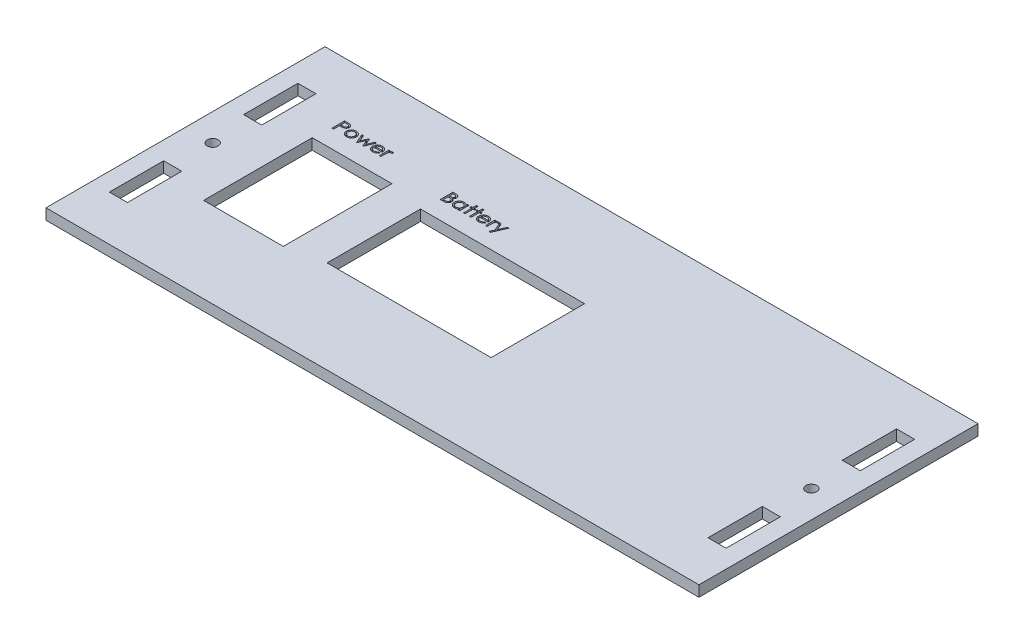
from build123d import *

# Parameters (mm, degrees)
SCHIZZO1_W                   = 180.34
SCHIZZO1_H                   = 77.07
ESTRUSIONE_ESTRUSIONE1_DEPTH = 3
SCHIZZO2_R                   = 1.5
SCHIZZO2_W                   = 5
SCHIZZO2_H                   = 15
TAGLIO_ESTRUSIONE1_DEPTH     = 4
SCHIZZO3_W                   = 45.3
SCHIZZO3_H                   = 25.8
SCHIZZO3_W_2                 = 22
SCHIZZO3_H_2                 = 30
TAGLIO_ESTRUSIONE2_DEPTH     = 4
TAGLIO_ESTRUSIONE3_DEPTH     = 1
TAGLIO_ESTRUSIONE4_DEPTH     = 1


with BuildPart() as part:
    # Schizzo1 → Estrusione-Estrusione1 (new body)
    with BuildSketch(Plane(origin=(0, 0, 0), x_dir=(1, 0, 0), z_dir=(0, 1, 0))):
        Rectangle(SCHIZZO1_W, SCHIZZO1_H)
    extrude(amount=ESTRUSIONE_ESTRUSIONE1_DEPTH)

    # Schizzo2 → Taglio-Estrusione1 (cut, through all)
    with BuildSketch(Plane(origin=(0, 0, 0), x_dir=(1, 0, 0), z_dir=(0, 1, 0))):
        with Locations((-82.67, 0)):
            Circle(SCHIZZO2_R)
        with Locations((82.67, 0)):
            Circle(SCHIZZO2_R)
        with Locations((-82.67, 18.535)):
            Rectangle(SCHIZZO2_W, SCHIZZO2_H)
        with Locations((-82.67, -18.535)):
            Rectangle(SCHIZZO2_W, SCHIZZO2_H)
        with Locations((82.67, -18.535)):
            Rectangle(SCHIZZO2_W, SCHIZZO2_H)
        with Locations((82.67, 18.535)):
            Rectangle(SCHIZZO2_W, SCHIZZO2_H)
    extrude(amount=TAGLIO_ESTRUSIONE1_DEPTH, mode=Mode.SUBTRACT)

    # Schizzo3 → Taglio-Estrusione2 (cut, through all)
    with BuildSketch(Plane(origin=(0, 0, 0), x_dir=(1, 0, 0), z_dir=(0, 1, 0))):
        with Locations((-15.52, 0)):
            Rectangle(SCHIZZO3_W, SCHIZZO3_H)
        with Locations((-59.17, 0)):
            Rectangle(SCHIZZO3_W_2, SCHIZZO3_H_2)
    extrude(amount=TAGLIO_ESTRUSIONE2_DEPTH, mode=Mode.SUBTRACT)

    # Schizzo4 → Taglio-Estrusione3 (cut)
    with BuildSketch(Plane(origin=(0, 3, 0), x_dir=(1, 0, 0), z_dir=(0, 1, 0))):
        with BuildLine():
            Line((-37.721282051, 21.4), (-37.010344551, 21.4))
            add(Edge.make_bspline(
                [(-37.010344551, 21.4), (-36.975512489, 21.399880445), (-36.907901877, 21.399648383), (-36.809468419, 21.393576376), (-36.716881837, 21.385217637), (-36.629900509, 21.374684472), (-36.549090313, 21.358760238), (-36.474003053, 21.341039616), (-36.404852856, 21.319273206), (-36.32181816, 21.285928555), (-36.22684833, 21.236763452), (-36.12618551, 21.162915024), (-36.038636629, 21.07645617), (-35.966219425, 20.977667295), (-35.908930469, 20.870498168), (-35.866837195, 20.757921064), (-35.841651906, 20.640627626), (-35.838334155, 20.560876083), (-35.836666667, 20.520793269)],
                knots=[0, 0, 0, 0, 0.000104477, 0.000202794, 0.000295723, 0.000383383, 0.000465474, 0.000542677, 0.000614743, 0.000682705, 0.000810972, 0.000934377, 0.001055841, 0.001178682, 0.001300389, 0.001419294, 0.00153824, 0.001658426, 0.001658426, 0.001658426, 0.001658426], degree=3))
            add(Edge.make_bspline(
                [(-35.836666667, 20.520793269), (-35.838097439, 20.483316811), (-35.840925182, 20.409249289), (-35.861017361, 20.300045305), (-35.894740632, 20.195158689), (-35.941805515, 20.096228704), (-35.998673946, 20.004881066), (-36.068761704, 19.927059819), (-36.147555195, 19.860768065), (-36.207610576, 19.828721119), (-36.237708333, 19.812660256)],
                knots=[0, 0, 0, 0, 0.000112398, 0.000222141, 0.000331895, 0.00044198, 0.000550119, 0.00065341, 0.000755032, 0.000857129, 0.000857129, 0.000857129, 0.000857129], degree=3))
            add(Edge.make_bspline(
                [(-36.237708333, 19.812660256), (-36.201903156, 19.800772337), (-36.132238439, 19.777642484), (-36.034681131, 19.731486439), (-35.946353959, 19.677660249), (-35.868124222, 19.614722255), (-35.799552695, 19.544896005), (-35.738426844, 19.47013794), (-35.686314196, 19.389282289), (-35.643948432, 19.302651098), (-35.60900148, 19.212570596), (-35.585697898, 19.11852298), (-35.570121078, 19.022079984), (-35.56833643, 18.956652487), (-35.567435897, 18.923637821)],
                knots=[0, 0, 0, 0, 0.000113096, 0.000220046, 0.00032298, 0.000422732, 0.000520399, 0.000616102, 0.000711981, 0.000808242, 0.000904992, 0.00100124, 0.001098415, 0.001197395, 0.001197395, 0.001197395, 0.001197395], degree=3))
            add(Edge.make_bspline(
                [(-35.567435897, 18.923637821), (-35.568373631, 18.88946805), (-35.570225923, 18.821972997), (-35.585135888, 18.722434596), (-35.610833484, 18.626804781), (-35.644974124, 18.534107631), (-35.690420006, 18.445507835), (-35.745386093, 18.360259095), (-35.810399726, 18.278738965), (-35.884095559, 18.201278669), (-35.966688213, 18.130332131), (-36.057305054, 18.068652309), (-36.155095664, 18.016330709), (-36.260040649, 17.973323162), (-36.372738829, 17.940781259), (-36.492313636, 17.916867379), (-36.619018961, 17.902850181), (-36.705789048, 17.900965328), (-36.750228365, 17.9)],
                knots=[0, 0, 0, 0, 0.000102481, 0.00020243, 0.000301067, 0.000399128, 0.000498213, 0.000599147, 0.000702951, 0.000810562, 0.000919461, 0.001028946, 0.001138734, 0.001251617, 0.001368536, 0.001490087, 0.001617066, 0.001750369, 0.001750369, 0.001750369, 0.001750369], degree=3))
            Line((-36.750228365, 17.9), (-37.721282051, 17.9))
            Line((-37.721282051, 17.9), (-37.721282051, 21.4))
        make_face()
        with BuildLine():
            Line((-37.272564103, 20.996153846), (-37.272564103, 19.964102564))
            Line((-37.272564103, 19.964102564), (-37.159683494, 19.964102564))
            add(Edge.make_bspline(
                [(-37.159683494, 19.964102564), (-37.130464212, 19.96408051), (-37.074338657, 19.964038149), (-36.993242775, 19.968072108), (-36.918393486, 19.972582628), (-36.84959971, 19.979447893), (-36.78722123, 19.988761286), (-36.730607698, 19.998736631), (-36.680586197, 20.012102039), (-36.622537206, 20.031433106), (-36.558319564, 20.062133955), (-36.489104124, 20.107314707), (-36.428771312, 20.161983159), (-36.377929364, 20.225144014), (-36.336204248, 20.294303656), (-36.306819661, 20.368471797), (-36.288265652, 20.446265232), (-36.286354631, 20.499420924), (-36.285384615, 20.526402244)],
                knots=[0, 0, 0, 0, 8.7643e-05, 0.000168348, 0.000243529, 0.000312595, 0.000375657, 0.000432725, 0.000484933, 0.000530829, 0.000616135, 0.000697613, 0.000778026, 0.000859274, 0.000940077, 0.001019366, 0.001097772, 0.001178596, 0.001178596, 0.001178596, 0.001178596], degree=3))
            add(Edge.make_bspline(
                [(-36.285384615, 20.526402244), (-36.285634902, 20.544200578), (-36.286124866, 20.579042867), (-36.294431679, 20.62944457), (-36.305994173, 20.677388781), (-36.323720561, 20.721922497), (-36.345587657, 20.763896296), (-36.372412414, 20.802990571), (-36.40502718, 20.838425413), (-36.441607342, 20.871956681), (-36.484090624, 20.901734181), (-36.532961437, 20.926550351), (-36.587438684, 20.948789004), (-36.6485148, 20.96558324), (-36.715635846, 20.979951636), (-36.78903247, 20.989351791), (-36.868631587, 20.994882044), (-36.923629504, 20.995719527), (-36.952151442, 20.996153846)],
                knots=[0, 0, 0, 0, 5.3327e-05, 0.000104393, 0.000152857, 0.000201031, 0.000247759, 0.00029463, 0.000342783, 0.000391927, 0.000443276, 0.000497842, 0.00055604, 0.000619506, 0.000687572, 0.000761842, 0.000841267, 0.000926829, 0.000926829, 0.000926829, 0.000926829], degree=3))
            Line((-36.952151442, 20.996153846), (-37.272564103, 20.996153846))
        make_face(mode=Mode.SUBTRACT)
        with BuildLine():
            Line((-37.272564103, 19.56025641), (-37.272564103, 18.303846154))
            Line((-37.272564103, 18.303846154), (-36.929014423, 18.303846154))
            add(Edge.make_bspline(
                [(-36.929014423, 18.303846154), (-36.898865922, 18.304238817), (-36.8406601, 18.304996906), (-36.756685706, 18.307296665), (-36.67906548, 18.313117782), (-36.607961618, 18.320659123), (-36.543018276, 18.330079436), (-36.485122777, 18.342963233), (-36.433096486, 18.356573094), (-36.373216733, 18.378807692), (-36.306200799, 18.413291383), (-36.233333251, 18.463240598), (-36.170069139, 18.524355432), (-36.115612678, 18.593476378), (-36.07127903, 18.668850002), (-36.039718232, 18.748563163), (-36.019692229, 18.831043445), (-36.01733736, 18.887067636), (-36.016153846, 18.915224359)],
                knots=[0, 0, 0, 0, 9.0456e-05, 0.000174637, 0.000251964, 0.000323893, 0.000389139, 0.000448685, 0.000501753, 0.000550333, 0.000640011, 0.000727145, 0.000814422, 0.000902789, 0.000990451, 0.001075729, 0.001159233, 0.001243604, 0.001243604, 0.001243604, 0.001243604], degree=3))
            add(Edge.make_bspline(
                [(-36.016153846, 18.915224359), (-36.017560683, 18.950470246), (-36.020323742, 19.019693993), (-36.048489164, 19.119385816), (-36.092537184, 19.212300006), (-36.154016566, 19.297120456), (-36.230779686, 19.372625552), (-36.322468733, 19.435368625), (-36.427765032, 19.484990943), (-36.503991972, 19.506875761), (-36.543397436, 19.518189103)],
                knots=[0, 0, 0, 0, 0.000105504, 0.000207213, 0.000308194, 0.000412682, 0.000519773, 0.000629654, 0.000744442, 0.000867284, 0.000867284, 0.000867284, 0.000867284], degree=3))
            add(Edge.make_bspline(
                [(-36.543397436, 19.518189103), (-36.559724083, 19.521647207), (-36.594778311, 19.529071951), (-36.651982829, 19.536884735), (-36.716883534, 19.545048825), (-36.790168434, 19.549908165), (-36.871453874, 19.555409586), (-36.961029012, 19.557471783), (-37.058708175, 19.559987803), (-37.12649469, 19.560164444), (-37.161786859, 19.56025641)],
                knots=[0, 0, 0, 0, 5.005e-05, 0.000107461, 0.00017312, 0.000246252, 0.00032773, 0.000417518, 0.000514996, 0.000620868, 0.000620868, 0.000620868, 0.000620868], degree=3))
            Line((-37.161786859, 19.56025641), (-37.272564103, 19.56025641))
        make_face(mode=Mode.SUBTRACT)
        with BuildLine():
            Line((-32.336666667, 20.502564103), (-32.336666667, 17.9))
            Line((-32.336666667, 17.9), (-32.785384615, 17.9))
            Line((-32.785384615, 17.9), (-32.785384615, 18.333994391))
            add(Edge.make_bspline(
                [(-32.785384615, 18.333994391), (-32.793361161, 18.315314052), (-32.809373824, 18.277813859), (-32.8413969, 18.225375017), (-32.878868795, 18.175715991), (-32.922459636, 18.129523627), (-32.971832724, 18.086646396), (-33.026900537, 18.047061761), (-33.088263386, 18.011609802), (-33.177227671, 17.967711362), (-33.296191519, 17.922173841), (-33.44661922, 17.884129375), (-33.603695085, 17.859106968), (-33.711001395, 17.856469181), (-33.765552885, 17.855128205)],
                knots=[0, 0, 0, 0, 6.0869e-05, 0.000122192, 0.000183751, 0.00024724, 0.000312339, 0.000379661, 0.000450367, 0.000524679, 0.000677152, 0.000831389, 0.000989546, 0.001153089, 0.001153089, 0.001153089, 0.001153089], degree=3))
            add(Edge.make_bspline(
                [(-33.765552885, 17.855128205), (-33.811418195, 17.856369648), (-33.901880305, 17.8588182), (-34.035096162, 17.877377496), (-34.163046225, 17.908263129), (-34.286037047, 17.951181697), (-34.403723815, 18.006961755), (-34.516158118, 18.075236832), (-34.62315312, 18.155893156), (-34.724122506, 18.246886124), (-34.815975801, 18.347259759), (-34.897283196, 18.453967095), (-34.965338438, 18.566807845), (-35.022103275, 18.684433455), (-35.065715225, 18.807887039), (-35.096427409, 18.936665013), (-35.115071566, 19.070795247), (-35.117489193, 19.161959259), (-35.118717949, 19.208293269)],
                knots=[0, 0, 0, 0, 0.000137565, 0.000271325, 0.000402605, 0.00053188, 0.000661407, 0.000792592, 0.000925805, 0.001062813, 0.001199774, 0.001333409, 0.001464594, 0.001594423, 0.001724592, 0.001856553, 0.001991008, 0.002129974, 0.002129974, 0.002129974, 0.002129974], degree=3))
            add(Edge.make_bspline(
                [(-35.118717949, 19.208293269), (-35.117551711, 19.253470911), (-35.115245014, 19.342827615), (-35.095522322, 19.474030275), (-35.065185966, 19.600705918), (-35.020287812, 19.721655844), (-34.96411646, 19.83813144), (-34.894863907, 19.949403726), (-34.812973435, 20.05561637), (-34.71988298, 20.155723156), (-34.617592203, 20.24648783), (-34.509854222, 20.327365345), (-34.396693123, 20.395606271), (-34.278312973, 20.451387748), (-34.154623307, 20.494308255), (-34.026197134, 20.52510673), (-33.8925365, 20.543792215), (-33.801837647, 20.546208001), (-33.755737179, 20.547435897)],
                knots=[0, 0, 0, 0, 0.000135464, 0.000267933, 0.00039717, 0.000525597, 0.000654163, 0.000784519, 0.000918021, 0.001055934, 0.001193986, 0.00132776, 0.001459545, 0.001589707, 0.001719643, 0.001851605, 0.001985365, 0.00212363, 0.00212363, 0.00212363, 0.00212363], degree=3))
            add(Edge.make_bspline(
                [(-33.755737179, 20.547435897), (-33.700008917, 20.545917648), (-33.590763033, 20.542941376), (-33.431183615, 20.516639038), (-33.279160064, 20.475742758), (-33.159921353, 20.426655708), (-33.071124943, 20.37985478), (-33.011005995, 20.341513262), (-32.956786609, 20.29998921), (-32.909973497, 20.25418783), (-32.86869729, 20.205610121), (-32.834226289, 20.153322912), (-32.805623648, 20.097676276), (-32.792155872, 20.058246013), (-32.785384615, 20.038421474)],
                knots=[0, 0, 0, 0, 0.000167079, 0.00032753, 0.000483844, 0.000638524, 0.000713173, 0.000784746, 0.000852203, 0.000917652, 0.00098085, 0.001043076, 0.00110516, 0.001167937, 0.001167937, 0.001167937, 0.001167937], degree=3))
            Line((-32.785384615, 20.038421474), (-32.785384615, 20.502564103))
            Line((-32.785384615, 20.502564103), (-32.336666667, 20.502564103))
        make_face()
        with BuildLine():
            add(Edge.make_bspline(
                [(-33.748725962, 20.143589744), (-33.788324706, 20.14232667), (-33.866733023, 20.139825695), (-33.982030498, 20.117225876), (-34.093230959, 20.080469814), (-34.199401325, 20.029204152), (-34.299716105, 19.965032549), (-34.389973385, 19.885265574), (-34.471135712, 19.792758526), (-34.541320308, 19.688149896), (-34.598622903, 19.57501791), (-34.639769592, 19.45545334), (-34.665053417, 19.331585329), (-34.668345206, 19.247205622), (-34.67, 19.20478766)],
                knots=[0, 0, 0, 0, 0.000118697, 0.000235028, 0.000350985, 0.000469209, 0.000587837, 0.000707086, 0.000829302, 0.000956089, 0.001084018, 0.001208629, 0.001334442, 0.001461624, 0.001461624, 0.001461624, 0.001461624], degree=3))
            add(Edge.make_bspline(
                [(-34.67, 19.20478766), (-34.668362239, 19.162366559), (-34.665113185, 19.078209948), (-34.639575836, 18.95409819), (-34.598068364, 18.834005517), (-34.539730846, 18.719882471), (-34.469189516, 18.614361337), (-34.387929728, 18.520499478), (-34.29672466, 18.440757759), (-34.1970887, 18.374441159), (-34.090399899, 18.323945187), (-33.980538566, 18.285956777), (-33.866937764, 18.26370269), (-33.790185842, 18.260558102), (-33.751530449, 18.258974359)],
                knots=[0, 0, 0, 0, 0.000127182, 0.000252308, 0.000378473, 0.000507344, 0.000635685, 0.00075843, 0.000878668, 0.000998064, 0.001116288, 0.001231803, 0.001346069, 0.001462011, 0.001462011, 0.001462011, 0.001462011], degree=3))
            add(Edge.make_bspline(
                [(-33.751530449, 18.258974359), (-33.708891792, 18.260431131), (-33.624378026, 18.263318589), (-33.499401711, 18.287352734), (-33.3785878, 18.326968045), (-33.262284392, 18.380672624), (-33.154650277, 18.448048041), (-33.057900062, 18.52674041), (-32.97608005, 18.617872304), (-32.906771277, 18.718185074), (-32.853118995, 18.828094688), (-32.813281577, 18.944533683), (-32.789616958, 19.068049653), (-32.786814078, 19.152568613), (-32.785384615, 19.195673077)],
                knots=[0, 0, 0, 0, 0.000127837, 0.000253385, 0.000380208, 0.000508506, 0.000636706, 0.000760231, 0.000881344, 0.001002889, 0.001124862, 0.001247029, 0.001371199, 0.001500435, 0.001500435, 0.001500435, 0.001500435], degree=3))
            add(Edge.make_bspline(
                [(-32.785384615, 19.195673077), (-32.786114094, 19.228671903), (-32.787553375, 19.293779438), (-32.801278882, 19.389113876), (-32.823168779, 19.480387326), (-32.852910436, 19.567664895), (-32.893035345, 19.650200105), (-32.940358037, 19.729218188), (-32.998138049, 19.803004777), (-33.062685987, 19.872652893), (-33.133776148, 19.936089876), (-33.209476286, 19.991766751), (-33.2897653, 20.03840592), (-33.373648125, 20.077227675), (-33.462033882, 20.106329427), (-33.553817335, 20.128663706), (-33.649987927, 20.141170097), (-33.715505585, 20.142775654), (-33.748725962, 20.143589744)],
                knots=[0, 0, 0, 0, 9.8948e-05, 0.000195226, 0.000288246, 0.000380264, 0.000471207, 0.000563073, 0.00065605, 0.000751796, 0.000847635, 0.000941452, 0.001033202, 0.001125753, 0.001218208, 0.00131191, 0.001408789, 0.001508437, 0.001508437, 0.001508437, 0.001508437], degree=3))
        make_face(mode=Mode.SUBTRACT)
        Polygon((-31.304615385, 21.48974359), (-30.855897436, 21.48974359), (-30.855897436, 20.502564103), (-30.407179487, 20.502564103), (-30.407179487, 20.098717949), (-30.855897436, 20.098717949), (-30.855897436, 17.9), (-31.304615385, 17.9), (-31.304615385, 20.098717949), (-31.753333333, 20.098717949), (-31.753333333, 20.502564103), (-31.304615385, 20.502564103), align=None)
        Polygon((-29.644358974, 21.48974359), (-29.195641026, 21.48974359), (-29.195641026, 20.502564103), (-28.746923077, 20.502564103), (-28.746923077, 20.098717949), (-29.195641026, 20.098717949), (-29.195641026, 17.9), (-29.644358974, 17.9), (-29.644358974, 20.098717949), (-30.093076923, 20.098717949), (-30.093076923, 20.502564103), (-29.644358974, 20.502564103), align=None)
        with BuildLine():
            Line((-26.159082532, 18.797435897), (-25.785384615, 18.61864984))
            add(Edge.make_bspline(
                [(-25.785384615, 18.61864984), (-25.809010227, 18.575713264), (-25.855019004, 18.492098104), (-25.93352693, 18.376635147), (-26.018727888, 18.275091936), (-26.109793751, 18.186344646), (-26.207860642, 18.110414222), (-26.311163494, 18.04305139), (-26.421893351, 17.986568005), (-26.538629041, 17.938287878), (-26.662902934, 17.901134528), (-26.794562028, 17.874740251), (-26.933875366, 17.858298432), (-27.02936196, 17.856201752), (-27.078253205, 17.855128205)],
                knots=[0, 0, 0, 0, 0.000146968, 0.000286208, 0.00041808, 0.000544021, 0.000666883, 0.000789597, 0.00091346, 0.001039233, 0.001168104, 0.001301893, 0.001441649, 0.001588291, 0.001588291, 0.001588291, 0.001588291], degree=3))
            add(Edge.make_bspline(
                [(-27.078253205, 17.855128205), (-27.12997422, 17.85619375), (-27.231003995, 17.858275142), (-27.377855545, 17.878734593), (-27.516423654, 17.90969504), (-27.646206357, 17.954535505), (-27.766702715, 18.013428941), (-27.879350535, 18.083749316), (-27.982825903, 18.167682165), (-28.076140685, 18.263814107), (-28.159032361, 18.367637776), (-28.233115694, 18.475062862), (-28.293710458, 18.587167164), (-28.344888855, 18.701786948), (-28.384284334, 18.820158423), (-28.412196367, 18.941762673), (-28.429724411, 19.066857371), (-28.431779853, 19.151444688), (-28.432820513, 19.194270833)],
                knots=[0, 0, 0, 0, 0.000155076, 0.00030292, 0.000443915, 0.000580503, 0.000713771, 0.000845465, 0.000978067, 0.001112429, 0.001246563, 0.001376271, 0.001503346, 0.001628281, 0.001752441, 0.001876935, 0.00200217, 0.002130597, 0.002130597, 0.002130597, 0.002130597], degree=3))
            add(Edge.make_bspline(
                [(-28.432820513, 19.194270833), (-28.431909352, 19.234283481), (-28.430102088, 19.313647593), (-28.414687847, 19.430856717), (-28.391189664, 19.544961696), (-28.357341052, 19.655496005), (-28.313534007, 19.76265419), (-28.26009722, 19.866585297), (-28.196994223, 19.967260265), (-28.1482361, 20.030393557), (-28.123625801, 20.062259615)],
                knots=[0, 0, 0, 0, 0.000119992, 0.000238002, 0.000354058, 0.000469164, 0.000584259, 0.000700907, 0.000819371, 0.000940105, 0.000940105, 0.000940105, 0.000940105], degree=3))
            add(Edge.make_bspline(
                [(-28.123625801, 20.062259615), (-28.090345096, 20.100923157), (-28.024747571, 20.177130456), (-27.912956534, 20.276250754), (-27.79315261, 20.360586772), (-27.664546438, 20.428665336), (-27.528091536, 20.482756513), (-27.383008687, 20.520155189), (-27.229726533, 20.543101737), (-27.124843043, 20.545970041), (-27.071241987, 20.547435897)],
                knots=[0, 0, 0, 0, 0.000152902, 0.000301376, 0.000446867, 0.000591463, 0.000736893, 0.000886204, 0.001039993, 0.001200735, 0.001200735, 0.001200735, 0.001200735], degree=3))
            add(Edge.make_bspline(
                [(-27.071241987, 20.547435897), (-27.01342573, 20.546103701), (-26.900547222, 20.543502765), (-26.736330081, 20.518887887), (-26.581438499, 20.480007065), (-26.436261379, 20.424339559), (-26.300505214, 20.352955146), (-26.174206222, 20.266145294), (-26.05712325, 20.163400461), (-25.989397274, 20.08372807), (-25.95505609, 20.043329327)],
                knots=[0, 0, 0, 0, 0.000173349, 0.00033844, 0.000496926, 0.000651614, 0.000803719, 0.000955993, 0.001110464, 0.001269361, 0.001269361, 0.001269361, 0.001269361], degree=3))
            add(Edge.make_bspline(
                [(-25.95505609, 20.043329327), (-25.931011616, 20.012009867), (-25.883076729, 19.949571624), (-25.823024007, 19.847261463), (-25.770794402, 19.739811955), (-25.727768032, 19.625824043), (-25.695414156, 19.505433817), (-25.670388549, 19.379502668), (-25.655957998, 19.247411787), (-25.652984335, 19.157377603), (-25.651470353, 19.111538462)],
                knots=[0, 0, 0, 0, 0.000118355, 0.000235951, 0.000355111, 0.000476478, 0.000600816, 0.000728693, 0.000861324, 0.000998888, 0.000998888, 0.000998888, 0.000998888], degree=3))
            Line((-25.651470353, 19.111538462), (-27.984803686, 19.111538462))
            add(Edge.make_bspline(
                [(-27.984803686, 19.111538462), (-27.983599962, 19.081792695), (-27.981236122, 19.023378765), (-27.966340556, 18.938068688), (-27.945671914, 18.85623335), (-27.916708107, 18.777999741), (-27.880041567, 18.703318464), (-27.835817394, 18.63223848), (-27.783366647, 18.565299832), (-27.724166181, 18.502690254), (-27.659573111, 18.445725464), (-27.591327677, 18.395676129), (-27.519943767, 18.35290522), (-27.4449754, 18.318961195), (-27.36714357, 18.291721885), (-27.286208287, 18.273329362), (-27.202293053, 18.260490191), (-27.145143729, 18.259484975), (-27.116113782, 18.258974359)],
                knots=[0, 0, 0, 0, 8.9219e-05, 0.000175206, 0.000259212, 0.000342176, 0.000424955, 0.000508415, 0.000592845, 0.000679639, 0.00076657, 0.000850851, 0.000933217, 0.001015729, 0.001097325, 0.001180146, 0.001264427, 0.001351436, 0.001351436, 0.001351436, 0.001351436], degree=3))
            add(Edge.make_bspline(
                [(-27.116113782, 18.258974359), (-27.084990536, 18.259559574), (-27.023006061, 18.260725077), (-26.931237302, 18.272820221), (-26.8407812, 18.289773019), (-26.75316227, 18.315463309), (-26.669043758, 18.345534318), (-26.591052888, 18.381427433), (-26.519873946, 18.421345631), (-26.4527792, 18.467525058), (-26.385935999, 18.52542373), (-26.315515173, 18.599876046), (-26.238673043, 18.692149402), (-26.186822779, 18.760739646), (-26.159082532, 18.797435897)],
                knots=[0, 0, 0, 0, 9.3315e-05, 0.000185845, 0.000277284, 0.00036916, 0.000459431, 0.000545077, 0.000626389, 0.000703989, 0.00078901, 0.000891157, 0.00101109, 0.001149081, 0.001149081, 0.001149081, 0.001149081], degree=3))
        make_face()
        with BuildLine():
            add(Edge.make_bspline(
                [(-26.099487179, 19.515384615), (-26.110857659, 19.544371821), (-26.133535271, 19.602184742), (-26.177195739, 19.684256266), (-26.228891864, 19.760902105), (-26.287177592, 19.833290991), (-26.355026278, 19.899892501), (-26.433533164, 19.959331493), (-26.521832697, 20.013226529), (-26.619950203, 20.058419665), (-26.724009331, 20.096124264), (-26.831945226, 20.123756061), (-26.942660966, 20.140233197), (-27.017434532, 20.142465027), (-27.055116186, 20.143589744)],
                knots=[0, 0, 0, 0, 9.3357e-05, 0.000186194, 0.000278172, 0.000370372, 0.000464573, 0.000562595, 0.000665162, 0.000774315, 0.00088609, 0.000996792, 0.001108043, 0.001221063, 0.001221063, 0.001221063, 0.001221063], degree=3))
            add(Edge.make_bspline(
                [(-27.055116186, 20.143589744), (-27.083887984, 20.142863894), (-27.140896895, 20.141425683), (-27.225140467, 20.131542886), (-27.306810171, 20.114756514), (-27.385867978, 20.090725758), (-27.462254694, 20.05977809), (-27.536404036, 20.022353989), (-27.608038309, 19.978344962), (-27.65297882, 19.944158151), (-27.675608974, 19.926943109)],
                knots=[0, 0, 0, 0, 8.6309e-05, 0.000171014, 0.000254067, 0.000336131, 0.000418545, 0.00050101, 0.000585065, 0.000670326, 0.000670326, 0.000670326, 0.000670326], degree=3))
            add(Edge.make_bspline(
                [(-27.675608974, 19.926943109), (-27.70434393, 19.901647995), (-27.763151914, 19.849879875), (-27.836155638, 19.75270686), (-27.901830088, 19.641298487), (-27.934740175, 19.558456343), (-27.951850962, 19.515384615)],
                knots=[0, 0, 0, 0, 0.000114575, 0.000234485, 0.000362674, 0.000501503, 0.000501503, 0.000501503, 0.000501503], degree=3))
            Line((-27.951850962, 19.515384615), (-26.099487179, 19.515384615))
        make_face(mode=Mode.SUBTRACT)
        with BuildLine():
            Line((-25.246923077, 20.502564103), (-24.798205128, 20.502564103))
            Line((-24.798205128, 20.502564103), (-24.798205128, 20.133072917))
            add(Edge.make_bspline(
                [(-24.798205128, 20.133072917), (-24.79549756, 20.149966016), (-24.79021277, 20.182938951), (-24.776882172, 20.230322614), (-24.758444238, 20.274314631), (-24.735268936, 20.314965055), (-24.707784562, 20.352428287), (-24.675712197, 20.386470293), (-24.639201034, 20.417567897), (-24.583962753, 20.453112014), (-24.511438504, 20.490706482), (-24.420440016, 20.523332794), (-24.327281736, 20.544001661), (-24.264055421, 20.546290128), (-24.23239984, 20.547435897)],
                knots=[0, 0, 0, 0, 5.1297e-05, 0.000100124, 0.000147262, 0.000194048, 0.000240184, 0.000286314, 0.000334073, 0.00038366, 0.000483063, 0.000578426, 0.000673033, 0.000767895, 0.000767895, 0.000767895, 0.000767895], degree=3))
            add(Edge.make_bspline(
                [(-24.23239984, 20.547435897), (-24.203768846, 20.545735685), (-24.143618661, 20.54216375), (-24.051225226, 20.518348411), (-23.953935443, 20.479042544), (-23.889673957, 20.443907866), (-23.855897436, 20.425440705)],
                knots=[0, 0, 0, 0, 8.5884e-05, 0.000180431, 0.000284587, 0.00039999, 0.00039999, 0.00039999, 0.00039999], degree=3))
            Line((-23.855897436, 20.425440705), (-24.06833734, 20.099419071))
            add(Edge.make_bspline(
                [(-24.06833734, 20.099419071), (-24.092569686, 20.106273931), (-24.136837664, 20.118796482), (-24.197856951, 20.131553766), (-24.246135533, 20.141222376), (-24.274439008, 20.142887061), (-24.286386218, 20.143589744)],
                knots=[0, 0, 0, 0, 7.5513e-05, 0.000137948, 0.000187052, 0.000222919, 0.000222919, 0.000222919, 0.000222919], degree=3))
            add(Edge.make_bspline(
                [(-24.286386218, 20.143589744), (-24.305962625, 20.142154169), (-24.347166215, 20.139132632), (-24.408630402, 20.115384327), (-24.471737208, 20.078744425), (-24.523729061, 20.037718289), (-24.565439111, 19.997617549), (-24.595280444, 19.960833648), (-24.62424264, 19.919203509), (-24.651431571, 19.87230556), (-24.676523382, 19.820100375), (-24.700253352, 19.763190078), (-24.723048048, 19.701359658), (-24.73561601, 19.657801852), (-24.742115385, 19.635276442)],
                knots=[0, 0, 0, 0, 5.8614e-05, 0.000123368, 0.000195287, 0.000277195, 0.000321321, 0.00036863, 0.000419004, 0.000473358, 0.000531055, 0.000592646, 0.000658297, 0.000728609, 0.000728609, 0.000728609, 0.000728609], degree=3))
            add(Edge.make_bspline(
                [(-24.742115385, 19.635276442), (-24.746861071, 19.61664213), (-24.75750873, 19.574833261), (-24.76753307, 19.503858549), (-24.777625898, 19.419049217), (-24.784725676, 19.320066033), (-24.791269285, 19.207191629), (-24.794991349, 19.080005947), (-24.798077852, 18.938610388), (-24.798161392, 18.839505448), (-24.798205128, 18.787620192)],
                knots=[0, 0, 0, 0, 5.765e-05, 0.000129346, 0.000214748, 0.000313907, 0.000426963, 0.000553936, 0.000695591, 0.000851241, 0.000851241, 0.000851241, 0.000851241], degree=3))
            Line((-24.798205128, 18.787620192), (-24.798205128, 17.9))
            Line((-24.798205128, 17.9), (-25.246923077, 17.9))
            Line((-25.246923077, 17.9), (-25.246923077, 20.502564103))
        make_face()
        Polygon((-23.900769231, 20.502564103), (-23.447143429, 20.502564103), (-22.626830929, 18.580088141), (-21.802311699, 20.502564103), (-21.343076923, 20.502564103), (-22.933922276, 16.957692308), (-23.388249199, 16.957692308), (-22.862407853, 18.158713942), align=None)
    extrude(amount=-TAGLIO_ESTRUSIONE3_DEPTH, mode=Mode.SUBTRACT)

    # Schizzo5 → Taglio-Estrusione4 (cut)
    with BuildSketch(Plane(origin=(0, 3, 0), x_dir=(1, 0, 0), z_dir=(0, 1, 0))):
        with BuildLine():
            Line((-69.721282051, 23.5), (-69.004034455, 23.5))
            add(Edge.make_bspline(
                [(-69.004034455, 23.5), (-68.956589121, 23.499974153), (-68.865662184, 23.499924617), (-68.735263232, 23.496567938), (-68.616962019, 23.493670846), (-68.510583749, 23.488102386), (-68.416370619, 23.480474665), (-68.334288809, 23.471505378), (-68.264250186, 23.461417408), (-68.222011407, 23.452297078), (-68.202652244, 23.448116987)],
                knots=[0, 0, 0, 0, 0.000142329, 0.000272768, 0.00039131, 0.000497328, 0.000592293, 0.000674829, 0.000745032, 0.000804433, 0.000804433, 0.000804433, 0.000804433], degree=3))
            add(Edge.make_bspline(
                [(-68.202652244, 23.448116987), (-68.175399632, 23.441108824), (-68.121638582, 23.427283866), (-68.044785162, 23.39878654), (-67.971861648, 23.366405202), (-67.903117014, 23.329570336), (-67.83925346, 23.28702804), (-67.778893162, 23.240806502), (-67.723892712, 23.188567902), (-67.672367839, 23.132846449), (-67.627159619, 23.072369421), (-67.586652924, 23.00918318), (-67.553079034, 22.942369961), (-67.525486977, 22.872178288), (-67.503917268, 22.798974125), (-67.488401865, 22.722524234), (-67.479078827, 22.642996256), (-67.47816019, 22.588800877), (-67.477692308, 22.561197917)],
                knots=[0, 0, 0, 0, 8.4368e-05, 0.000166432, 0.000245522, 0.000323637, 0.000400059, 0.00047551, 0.000551403, 0.000627335, 0.000702917, 0.000777608, 0.000852234, 0.000926837, 0.001003596, 0.001080872, 0.001160622, 0.001243402, 0.001243402, 0.001243402, 0.001243402], degree=3))
            add(Edge.make_bspline(
                [(-67.477692308, 22.561197917), (-67.478170456, 22.533596243), (-67.47911327, 22.479171129), (-67.488377434, 22.399167722), (-67.503906898, 22.322559015), (-67.524843509, 22.249006576), (-67.552358862, 22.178967838), (-67.58523743, 22.111851512), (-67.624981314, 22.048418008), (-67.670353644, 21.98822703), (-67.721591952, 21.932203586), (-67.777953653, 21.880560318), (-67.840179603, 21.834199154), (-67.907631605, 21.79228796), (-67.980074619, 21.7540918), (-68.058237429, 21.721238911), (-68.141771313, 21.69324512), (-68.199745714, 21.678360054), (-68.229294872, 21.670773237)],
                knots=[0, 0, 0, 0, 8.278e-05, 0.000163226, 0.000241189, 0.000317079, 0.000392334, 0.000466647, 0.000540966, 0.000616547, 0.000692479, 0.000768411, 0.000845534, 0.000924907, 0.001006445, 0.001090959, 0.001178979, 0.00127048, 0.00127048, 0.00127048, 0.00127048], degree=3))
            add(Edge.make_bspline(
                [(-68.229294872, 21.670773237), (-68.250981654, 21.666071387), (-68.298290921, 21.655814397), (-68.376797803, 21.645141265), (-68.468274347, 21.636397204), (-68.57300967, 21.62878971), (-68.690574463, 21.622399347), (-68.821490194, 21.618595316), (-68.965458282, 21.615525746), (-69.065964867, 21.615432951), (-69.118317308, 21.615384615)],
                knots=[0, 0, 0, 0, 6.6551e-05, 0.00014518, 0.000237478, 0.00034223, 0.000460187, 0.000590663, 0.000735122, 0.000892175, 0.000892175, 0.000892175, 0.000892175], degree=3))
            Line((-69.118317308, 21.615384615), (-69.272564103, 21.615384615))
            Line((-69.272564103, 21.615384615), (-69.272564103, 20))
            Line((-69.272564103, 20), (-69.721282051, 20))
            Line((-69.721282051, 20), (-69.721282051, 23.5))
        make_face()
        with BuildLine():
            Line((-69.272564103, 23.096153846), (-69.272564103, 22.017828526))
            Line((-69.272564103, 22.017828526), (-68.76775641, 22.012219551))
            add(Edge.make_bspline(
                [(-68.76775641, 22.012219551), (-68.739243058, 22.012595538), (-68.684306807, 22.013319945), (-68.605029503, 22.015835172), (-68.53211122, 22.020947202), (-68.465411104, 22.026909266), (-68.404794412, 22.035268109), (-68.350534036, 22.045700349), (-68.302167314, 22.057421536), (-68.246859279, 22.075849837), (-68.184950573, 22.104624168), (-68.119134856, 22.148527848), (-68.06112057, 22.201033412), (-68.01320952, 22.262832359), (-67.97465269, 22.330922638), (-67.945992426, 22.403698577), (-67.9297702, 22.481025373), (-67.927539726, 22.533781892), (-67.926410256, 22.560496795)],
                knots=[0, 0, 0, 0, 8.5548e-05, 0.000164825, 0.000237906, 0.000304811, 0.000365692, 0.000421381, 0.000470525, 0.000514868, 0.000596107, 0.000674473, 0.000751395, 0.000829799, 0.000907979, 0.000985449, 0.001063555, 0.001143679, 0.001143679, 0.001143679, 0.001143679], degree=3))
            add(Edge.make_bspline(
                [(-67.926410256, 22.560496795), (-67.927547885, 22.586279417), (-67.929804329, 22.637418277), (-67.946111352, 22.712630528), (-67.974784844, 22.783971677), (-68.013404474, 22.851105469), (-68.060334581, 22.912466761), (-68.115925525, 22.965252645), (-68.178839085, 23.008393416), (-68.237573734, 23.036024317), (-68.289944709, 23.054005996), (-68.336102195, 23.064568978), (-68.388246051, 23.074445219), (-68.446700077, 23.082911935), (-68.511518653, 23.089018271), (-68.582623644, 23.092935154), (-68.659757279, 23.096004647), (-68.713299099, 23.096102837), (-68.741113782, 23.096153846)],
                knots=[0, 0, 0, 0, 7.7327e-05, 0.000153375, 0.00022954, 0.000307111, 0.000385084, 0.000460467, 0.000536117, 0.000612953, 0.000654414, 0.000702028, 0.000754832, 0.00081363, 0.000879139, 0.000950077, 0.001027251, 0.001110688, 0.001110688, 0.001110688, 0.001110688], degree=3))
            Line((-68.741113782, 23.096153846), (-69.272564103, 23.096153846))
        make_face(mode=Mode.SUBTRACT)
        with BuildLine():
            add(Edge.make_bspline(
                [(-65.658982372, 22.647435897), (-65.607042429, 22.646013529), (-65.505353824, 22.643228799), (-65.356556584, 22.623636908), (-65.215258492, 22.589596658), (-65.081054577, 22.543006368), (-64.954497156, 22.481966588), (-64.835270131, 22.408118995), (-64.723799772, 22.320027655), (-64.656654198, 22.252481578), (-64.622724359, 22.218349359)],
                knots=[0, 0, 0, 0, 0.000155807, 0.00030504, 0.000449247, 0.000591161, 0.000730395, 0.000869892, 0.001011145, 0.001155435, 0.001155435, 0.001155435, 0.001155435], degree=3))
            add(Edge.make_bspline(
                [(-64.622724359, 22.218349359), (-64.592635497, 22.184518286), (-64.533478449, 22.118003758), (-64.457041136, 22.010712667), (-64.391945387, 21.900343439), (-64.339281179, 21.786064), (-64.297304, 21.668396927), (-64.268192523, 21.546877278), (-64.249860314, 21.421734944), (-64.247910091, 21.337103226), (-64.246923077, 21.294270833)],
                knots=[0, 0, 0, 0, 0.000135744, 0.000266884, 0.000394467, 0.000519631, 0.00064381, 0.000768628, 0.000893958, 0.001022386, 0.001022386, 0.001022386, 0.001022386], degree=3))
            add(Edge.make_bspline(
                [(-64.246923077, 21.294270833), (-64.248156701, 21.251202095), (-64.250601574, 21.165845843), (-64.269526291, 21.039756461), (-64.299456076, 20.917025605), (-64.342510891, 20.798213576), (-64.397921432, 20.683191461), (-64.464397192, 20.571259587), (-64.544545622, 20.463907741), (-64.634660524, 20.360824663), (-64.734803697, 20.265726104), (-64.844093099, 20.182468224), (-64.96118893, 20.112009898), (-65.085879754, 20.054012972), (-65.218760237, 20.010188539), (-65.358543138, 19.977733808), (-65.506306877, 19.958567194), (-65.607276526, 19.95629287), (-65.658982372, 19.955128205)],
                knots=[0, 0, 0, 0, 0.000129161, 0.000255978, 0.000381644, 0.000507616, 0.000634309, 0.00076417, 0.000897527, 0.001035639, 0.001174511, 0.001311093, 0.001446966, 0.001583735, 0.00172275, 0.001865952, 0.002013704, 0.002168781, 0.002168781, 0.002168781, 0.002168781], degree=3))
            add(Edge.make_bspline(
                [(-65.658982372, 19.955128205), (-65.708363752, 19.956262397), (-65.805165554, 19.958485743), (-65.946622593, 19.978224188), (-66.081512296, 20.008347283), (-66.208850952, 20.053161634), (-66.329687568, 20.109202859), (-66.443213805, 20.178710857), (-66.550304087, 20.260031977), (-66.648164856, 20.354120918), (-66.73736211, 20.455269904), (-66.8147839, 20.562652976), (-66.881373935, 20.673773577), (-66.935510674, 20.789571626), (-66.976996435, 20.91000549), (-67.007372003, 21.034081297), (-67.025110084, 21.162884318), (-67.027673653, 21.250046428), (-67.028974359, 21.294270833)],
                knots=[0, 0, 0, 0, 0.000148071, 0.000290262, 0.000427684, 0.000562055, 0.000694418, 0.000826566, 0.000960625, 0.001097006, 0.001233139, 0.001364688, 0.001493588, 0.00162125, 0.001747415, 0.001875123, 0.002003926, 0.002136588, 0.002136588, 0.002136588, 0.002136588], degree=3))
            add(Edge.make_bspline(
                [(-67.028974359, 21.294270833), (-67.027914996, 21.338025415), (-67.025827842, 21.4242306), (-67.008718741, 21.551337962), (-66.979689895, 21.673469524), (-66.940556946, 21.791613682), (-66.888882119, 21.904870868), (-66.826058835, 22.013880158), (-66.752655213, 22.119044037), (-66.695436038, 22.183595601), (-66.666494391, 22.216245994)],
                knots=[0, 0, 0, 0, 0.00013123, 0.000258548, 0.000383885, 0.00050738, 0.000631322, 0.000756636, 0.000884437, 0.001015239, 0.001015239, 0.001015239, 0.001015239], degree=3))
            add(Edge.make_bspline(
                [(-66.666494391, 22.216245994), (-66.632825363, 22.250639716), (-66.566448811, 22.318444964), (-66.455965842, 22.406354353), (-66.339400574, 22.481308848), (-66.215580282, 22.541580307), (-66.085950029, 22.590006813), (-65.949236151, 22.623382156), (-65.806101126, 22.643223129), (-65.708591814, 22.646015323), (-65.658982372, 22.647435897)],
                knots=[0, 0, 0, 0, 0.000144276, 0.000284432, 0.000422523, 0.000559234, 0.000696769, 0.000836888, 0.000980563, 0.001129366, 0.001129366, 0.001129366, 0.001129366], degree=3))
        make_face()
        with BuildLine():
            add(Edge.make_bspline(
                [(-65.660384615, 22.243589744), (-65.690343953, 22.242791417), (-65.749829817, 22.241206298), (-65.837447625, 22.22823539), (-65.922608251, 22.207260238), (-66.004377198, 22.176807882), (-66.083988695, 22.138751628), (-66.16010478, 22.091350998), (-66.234440901, 22.036529711), (-66.304290867, 21.973048137), (-66.369279289, 21.903939169), (-66.425586502, 21.828992793), (-66.473755748, 21.750310342), (-66.51233227, 21.666898647), (-66.542812239, 21.579323936), (-66.564139529, 21.487417944), (-66.578196451, 21.391223919), (-66.579560347, 21.325638805), (-66.58025641, 21.292167468)],
                knots=[0, 0, 0, 0, 8.9842e-05, 0.000178386, 0.00026511, 0.000352506, 0.000439682, 0.000529388, 0.000621095, 0.000716412, 0.000812158, 0.000905267, 0.000997133, 0.001088411, 0.001180429, 0.001274813, 0.001371091, 0.00147144, 0.00147144, 0.00147144, 0.00147144], degree=3))
            add(Edge.make_bspline(
                [(-66.58025641, 21.292167468), (-66.578662686, 21.248574327), (-66.575526193, 21.162781867), (-66.549896515, 21.03711771), (-66.509220845, 20.917020401), (-66.452429179, 20.804057021), (-66.383003121, 20.700708685), (-66.302076209, 20.610232859), (-66.212742748, 20.531909347), (-66.113278038, 20.469012594), (-66.007092338, 20.41978393), (-65.895622797, 20.384737683), (-65.779497975, 20.362834451), (-65.700445401, 20.360272604), (-65.660384615, 20.358974359)],
                knots=[0, 0, 0, 0, 0.00013068, 0.000257181, 0.000383118, 0.000510106, 0.000635338, 0.000755515, 0.000873314, 0.000990594, 0.001107286, 0.001223478, 0.00134037, 0.001460467, 0.001460467, 0.001460467, 0.001460467], degree=3))
            add(Edge.make_bspline(
                [(-65.660384615, 20.358974359), (-65.61704831, 20.360455055), (-65.531651829, 20.363372844), (-65.40657695, 20.386563068), (-65.287130716, 20.423797639), (-65.174150101, 20.475691764), (-65.06929818, 20.541434524), (-64.975538549, 20.621223572), (-64.8933663, 20.713736138), (-64.823006136, 20.816855702), (-64.766187289, 20.92874096), (-64.725394426, 21.046164237), (-64.700651352, 21.16797497), (-64.69732389, 21.250453797), (-64.695641026, 21.292167468)],
                knots=[0, 0, 0, 0, 0.000129937, 0.000256047, 0.000380227, 0.00050446, 0.000627979, 0.00075034, 0.000872496, 0.000998122, 0.001123858, 0.001247806, 0.001370045, 0.001495128, 0.001495128, 0.001495128, 0.001495128], degree=3))
            add(Edge.make_bspline(
                [(-64.695641026, 21.292167468), (-64.69637225, 21.324466651), (-64.697814687, 21.388181116), (-64.711582007, 21.481922709), (-64.733926102, 21.572188116), (-64.765677506, 21.65857419), (-64.805885822, 21.74138144), (-64.855357202, 21.820256854), (-64.913916374, 21.895576404), (-64.980672555, 21.966121063), (-65.053036792, 22.030983728), (-65.129499009, 22.088264989), (-65.209902291, 22.135839098), (-65.293132234, 22.175930261), (-65.380362879, 22.205721543), (-65.470697756, 22.227547058), (-65.564367584, 22.24144468), (-65.628084294, 22.24286814), (-65.660384615, 22.243589744)],
                knots=[0, 0, 0, 0, 9.6846e-05, 0.000191042, 0.000283548, 0.000375376, 0.000466624, 0.000559225, 0.00065417, 0.000752377, 0.000850195, 0.000945409, 0.001038476, 0.001130052, 0.00122207, 0.001314408, 0.001408604, 0.00150545, 0.00150545, 0.00150545, 0.00150545], degree=3))
        make_face(mode=Mode.SUBTRACT)
        Polygon((-64.022564103, 22.602564103), (-63.571041667, 22.602564103), (-62.855897436, 20.806290064), (-62.072043269, 22.602564103), (-61.929014423, 22.602564103), (-61.155677083, 20.807692308), (-60.434923878, 22.602564103), (-59.984102564, 22.602564103), (-61.079254808, 20), (-61.223685897, 20), (-62.006137821, 21.806089744), (-62.796302083, 20), (-62.941434295, 20), align=None)
        with BuildLine():
            Line((-57.530877404, 20.897435897), (-57.157179487, 20.71864984))
            add(Edge.make_bspline(
                [(-57.157179487, 20.71864984), (-57.180805099, 20.675713264), (-57.226813876, 20.592098104), (-57.305321802, 20.476635147), (-57.39052276, 20.375091936), (-57.481588623, 20.286344646), (-57.579655514, 20.210414222), (-57.682958366, 20.14305139), (-57.793688223, 20.086568005), (-57.910423913, 20.038287878), (-58.034697805, 20.001134528), (-58.1663569, 19.974740251), (-58.305670238, 19.958298432), (-58.401156832, 19.956201752), (-58.450048077, 19.955128205)],
                knots=[0, 0, 0, 0, 0.000146968, 0.000286208, 0.00041808, 0.000544021, 0.000666883, 0.000789597, 0.00091346, 0.001039233, 0.001168104, 0.001301893, 0.001441649, 0.001588291, 0.001588291, 0.001588291, 0.001588291], degree=3))
            add(Edge.make_bspline(
                [(-58.450048077, 19.955128205), (-58.501769092, 19.95619375), (-58.602798866, 19.958275142), (-58.749650417, 19.978734593), (-58.888218526, 20.00969504), (-59.018001229, 20.054535505), (-59.138497587, 20.113428941), (-59.251145407, 20.183749316), (-59.354620774, 20.267682165), (-59.447935557, 20.363814107), (-59.530827232, 20.467637776), (-59.604910565, 20.575062862), (-59.66550533, 20.687167164), (-59.716683727, 20.801786948), (-59.756079206, 20.920158423), (-59.783991239, 21.041762673), (-59.801519283, 21.166857371), (-59.803574725, 21.251444688), (-59.804615385, 21.294270833)],
                knots=[0, 0, 0, 0, 0.000155076, 0.00030292, 0.000443915, 0.000580503, 0.000713771, 0.000845465, 0.000978067, 0.001112429, 0.001246563, 0.001376271, 0.001503346, 0.001628281, 0.001752441, 0.001876935, 0.00200217, 0.002130597, 0.002130597, 0.002130597, 0.002130597], degree=3))
            add(Edge.make_bspline(
                [(-59.804615385, 21.294270833), (-59.803704224, 21.334283481), (-59.80189696, 21.413647593), (-59.786482719, 21.530856717), (-59.762984535, 21.644961696), (-59.729135924, 21.755496005), (-59.685328879, 21.86265419), (-59.631892092, 21.966585297), (-59.568789094, 22.067260265), (-59.520030971, 22.130393557), (-59.495420673, 22.162259615)],
                knots=[0, 0, 0, 0, 0.000119992, 0.000238002, 0.000354058, 0.000469164, 0.000584259, 0.000700907, 0.000819371, 0.000940105, 0.000940105, 0.000940105, 0.000940105], degree=3))
            add(Edge.make_bspline(
                [(-59.495420673, 22.162259615), (-59.462139968, 22.200923157), (-59.396542443, 22.277130456), (-59.284751405, 22.376250754), (-59.164947482, 22.460586772), (-59.03634131, 22.528665336), (-58.899886408, 22.582756513), (-58.754803559, 22.620155189), (-58.601521405, 22.643101737), (-58.496637915, 22.645970041), (-58.443036859, 22.647435897)],
                knots=[0, 0, 0, 0, 0.000152902, 0.000301376, 0.000446867, 0.000591463, 0.000736893, 0.000886204, 0.001039993, 0.001200735, 0.001200735, 0.001200735, 0.001200735], degree=3))
            add(Edge.make_bspline(
                [(-58.443036859, 22.647435897), (-58.385220602, 22.646103701), (-58.272342094, 22.643502765), (-58.108124953, 22.618887887), (-57.953233371, 22.580007065), (-57.808056251, 22.524339559), (-57.672300086, 22.452955146), (-57.546001094, 22.366145294), (-57.428918122, 22.263400461), (-57.361192146, 22.18372807), (-57.326850962, 22.143329327)],
                knots=[0, 0, 0, 0, 0.000173349, 0.00033844, 0.000496926, 0.000651614, 0.000803719, 0.000955993, 0.001110464, 0.001269361, 0.001269361, 0.001269361, 0.001269361], degree=3))
            add(Edge.make_bspline(
                [(-57.326850962, 22.143329327), (-57.302806487, 22.112009867), (-57.254871601, 22.049571624), (-57.194818879, 21.947261463), (-57.142589274, 21.839811955), (-57.099562904, 21.725824043), (-57.067209028, 21.605433817), (-57.042183421, 21.479502668), (-57.02775287, 21.347411787), (-57.024779207, 21.257377603), (-57.023265224, 21.211538462)],
                knots=[0, 0, 0, 0, 0.000118355, 0.000235951, 0.000355111, 0.000476478, 0.000600816, 0.000728693, 0.000861324, 0.000998888, 0.000998888, 0.000998888, 0.000998888], degree=3))
            Line((-57.023265224, 21.211538462), (-59.356598558, 21.211538462))
            add(Edge.make_bspline(
                [(-59.356598558, 21.211538462), (-59.355394834, 21.181792695), (-59.353030993, 21.123378765), (-59.338135427, 21.038068688), (-59.317466786, 20.95623335), (-59.288502979, 20.877999741), (-59.251836439, 20.803318464), (-59.207612266, 20.73223848), (-59.155161519, 20.665299832), (-59.095961052, 20.602690254), (-59.031367983, 20.545725464), (-58.963122549, 20.495676129), (-58.891738639, 20.45290522), (-58.816770272, 20.418961195), (-58.738938442, 20.391721885), (-58.658003159, 20.373329362), (-58.574087925, 20.360490191), (-58.516938601, 20.359484975), (-58.487908654, 20.358974359)],
                knots=[0, 0, 0, 0, 8.9219e-05, 0.000175206, 0.000259212, 0.000342176, 0.000424955, 0.000508415, 0.000592845, 0.000679639, 0.00076657, 0.000850851, 0.000933217, 0.001015729, 0.001097325, 0.001180146, 0.001264427, 0.001351436, 0.001351436, 0.001351436, 0.001351436], degree=3))
            add(Edge.make_bspline(
                [(-58.487908654, 20.358974359), (-58.456785408, 20.359559574), (-58.394800932, 20.360725077), (-58.303032174, 20.372820221), (-58.212576071, 20.389773019), (-58.124957142, 20.415463309), (-58.04083863, 20.445534318), (-57.96284776, 20.481427433), (-57.891668817, 20.521345631), (-57.824574072, 20.567525058), (-57.757730871, 20.62542373), (-57.687310045, 20.699876046), (-57.610467915, 20.792149402), (-57.558617651, 20.860739646), (-57.530877404, 20.897435897)],
                knots=[0, 0, 0, 0, 9.3315e-05, 0.000185845, 0.000277284, 0.00036916, 0.000459431, 0.000545077, 0.000626389, 0.000703989, 0.00078901, 0.000891157, 0.00101109, 0.001149081, 0.001149081, 0.001149081, 0.001149081], degree=3))
        make_face()
        with BuildLine():
            add(Edge.make_bspline(
                [(-57.471282051, 21.615384615), (-57.482652531, 21.644371821), (-57.505330143, 21.702184742), (-57.548990611, 21.784256266), (-57.600686736, 21.860902105), (-57.658972463, 21.933290991), (-57.72682115, 21.999892501), (-57.805328036, 22.059331493), (-57.893627569, 22.113226529), (-57.991745075, 22.158419665), (-58.095804203, 22.196124264), (-58.203740098, 22.223756061), (-58.314455838, 22.240233197), (-58.389229404, 22.242465027), (-58.426911058, 22.243589744)],
                knots=[0, 0, 0, 0, 9.3357e-05, 0.000186194, 0.000278172, 0.000370372, 0.000464573, 0.000562595, 0.000665162, 0.000774315, 0.00088609, 0.000996792, 0.001108043, 0.001221063, 0.001221063, 0.001221063, 0.001221063], degree=3))
            add(Edge.make_bspline(
                [(-58.426911058, 22.243589744), (-58.455682856, 22.242863894), (-58.512691766, 22.241425683), (-58.596935339, 22.231542886), (-58.678605043, 22.214756514), (-58.75766285, 22.190725758), (-58.834049566, 22.15977809), (-58.908198908, 22.122353989), (-58.979833181, 22.078344962), (-59.024773692, 22.044158151), (-59.047403846, 22.026943109)],
                knots=[0, 0, 0, 0, 8.6309e-05, 0.000171014, 0.000254067, 0.000336131, 0.000418545, 0.00050101, 0.000585065, 0.000670326, 0.000670326, 0.000670326, 0.000670326], degree=3))
            add(Edge.make_bspline(
                [(-59.047403846, 22.026943109), (-59.076138801, 22.001647995), (-59.134946785, 21.949879875), (-59.20795051, 21.85270686), (-59.27362496, 21.741298487), (-59.306535047, 21.658456343), (-59.323645833, 21.615384615)],
                knots=[0, 0, 0, 0, 0.000114575, 0.000234485, 0.000362674, 0.000501503, 0.000501503, 0.000501503, 0.000501503], degree=3))
            Line((-59.323645833, 21.615384615), (-57.471282051, 21.615384615))
        make_face(mode=Mode.SUBTRACT)
        with BuildLine():
            Line((-56.618717949, 22.602564103), (-56.17, 22.602564103))
            Line((-56.17, 22.602564103), (-56.17, 22.233072917))
            add(Edge.make_bspline(
                [(-56.17, 22.233072917), (-56.167292431, 22.249966016), (-56.162007641, 22.282938951), (-56.148677044, 22.330322614), (-56.13023911, 22.374314631), (-56.107063808, 22.414965055), (-56.079579434, 22.452428287), (-56.047507069, 22.486470293), (-56.010995906, 22.517567897), (-55.955757624, 22.553112014), (-55.883233376, 22.590706482), (-55.792234888, 22.623332794), (-55.699076608, 22.644001661), (-55.635850293, 22.646290128), (-55.604194712, 22.647435897)],
                knots=[0, 0, 0, 0, 5.1297e-05, 0.000100124, 0.000147262, 0.000194048, 0.000240184, 0.000286314, 0.000334073, 0.00038366, 0.000483063, 0.000578426, 0.000673033, 0.000767895, 0.000767895, 0.000767895, 0.000767895], degree=3))
            add(Edge.make_bspline(
                [(-55.604194712, 22.647435897), (-55.575563718, 22.645735685), (-55.515413533, 22.64216375), (-55.423020098, 22.618348411), (-55.325730315, 22.579042544), (-55.261468829, 22.543907866), (-55.227692308, 22.525440705)],
                knots=[0, 0, 0, 0, 8.5884e-05, 0.000180431, 0.000284587, 0.00039999, 0.00039999, 0.00039999, 0.00039999], degree=3))
            Line((-55.227692308, 22.525440705), (-55.440132212, 22.199419071))
            add(Edge.make_bspline(
                [(-55.440132212, 22.199419071), (-55.464364557, 22.206273931), (-55.508632536, 22.218796482), (-55.569651823, 22.231553766), (-55.617930405, 22.241222376), (-55.64623388, 22.242887061), (-55.65818109, 22.243589744)],
                knots=[0, 0, 0, 0, 7.5513e-05, 0.000137948, 0.000187052, 0.000222919, 0.000222919, 0.000222919, 0.000222919], degree=3))
            add(Edge.make_bspline(
                [(-55.65818109, 22.243589744), (-55.677757496, 22.242154169), (-55.718961087, 22.239132632), (-55.780425274, 22.215384327), (-55.843532079, 22.178744425), (-55.895523933, 22.137718289), (-55.937233983, 22.097617549), (-55.967075316, 22.060833648), (-55.996037511, 22.019203509), (-56.023226443, 21.97230556), (-56.048318254, 21.920100375), (-56.072048224, 21.863190078), (-56.09484292, 21.801359658), (-56.107410882, 21.757801852), (-56.113910256, 21.735276442)],
                knots=[0, 0, 0, 0, 5.8614e-05, 0.000123368, 0.000195287, 0.000277195, 0.000321321, 0.00036863, 0.000419004, 0.000473358, 0.000531055, 0.000592646, 0.000658297, 0.000728609, 0.000728609, 0.000728609, 0.000728609], degree=3))
            add(Edge.make_bspline(
                [(-56.113910256, 21.735276442), (-56.118655943, 21.71664213), (-56.129303602, 21.674833261), (-56.139327941, 21.603858549), (-56.14942077, 21.519049217), (-56.156520548, 21.420066033), (-56.163064157, 21.307191629), (-56.166786221, 21.180005947), (-56.169872724, 21.038610388), (-56.169956264, 20.939505448), (-56.17, 20.887620192)],
                knots=[0, 0, 0, 0, 5.765e-05, 0.000129346, 0.000214748, 0.000313907, 0.000426963, 0.000553936, 0.000695591, 0.000851241, 0.000851241, 0.000851241, 0.000851241], degree=3))
            Line((-56.17, 20.887620192), (-56.17, 20))
            Line((-56.17, 20), (-56.618717949, 20))
            Line((-56.618717949, 20), (-56.618717949, 22.602564103))
        make_face()
    extrude(amount=-TAGLIO_ESTRUSIONE4_DEPTH, mode=Mode.SUBTRACT)


solid = part.part
